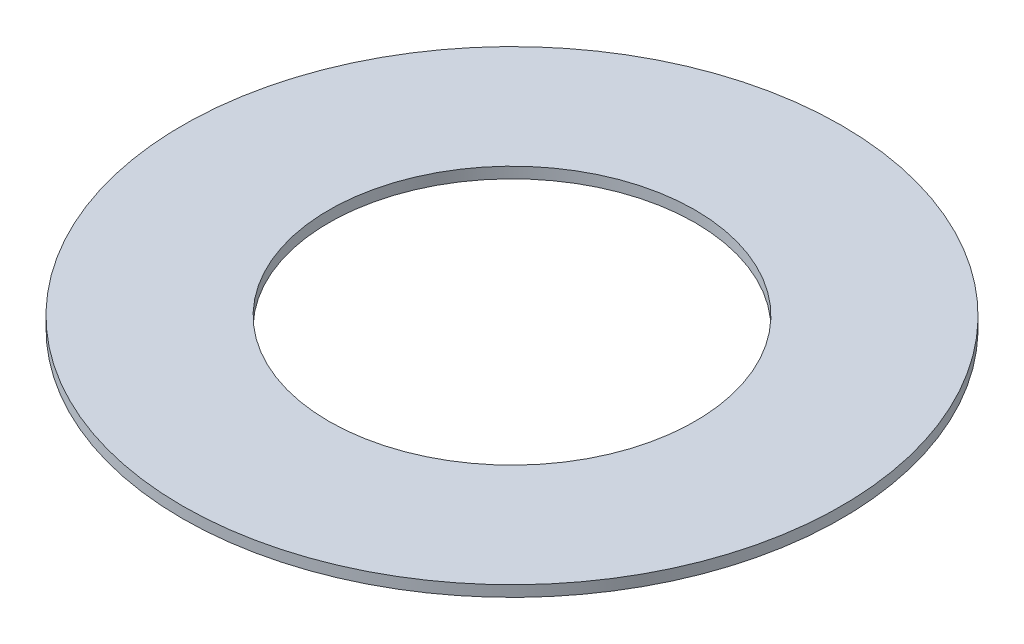
from build123d import *

# Parameters (mm, degrees)
SKETCH1_R           = 9
SKETCH1_R_2         = 5
BOSS_EXTRUDE1_DEPTH = 0.3


with BuildPart() as part:
    # Sketch1 → Boss-Extrude1 (new body)
    with BuildSketch(Plane(origin=(0, 0, 0), x_dir=(1, 0, 0), z_dir=(0, 1, 0))):
        Circle(SKETCH1_R)
        Circle(SKETCH1_R_2, mode=Mode.SUBTRACT)
    extrude(amount=BOSS_EXTRUDE1_DEPTH)


solid = part.part
